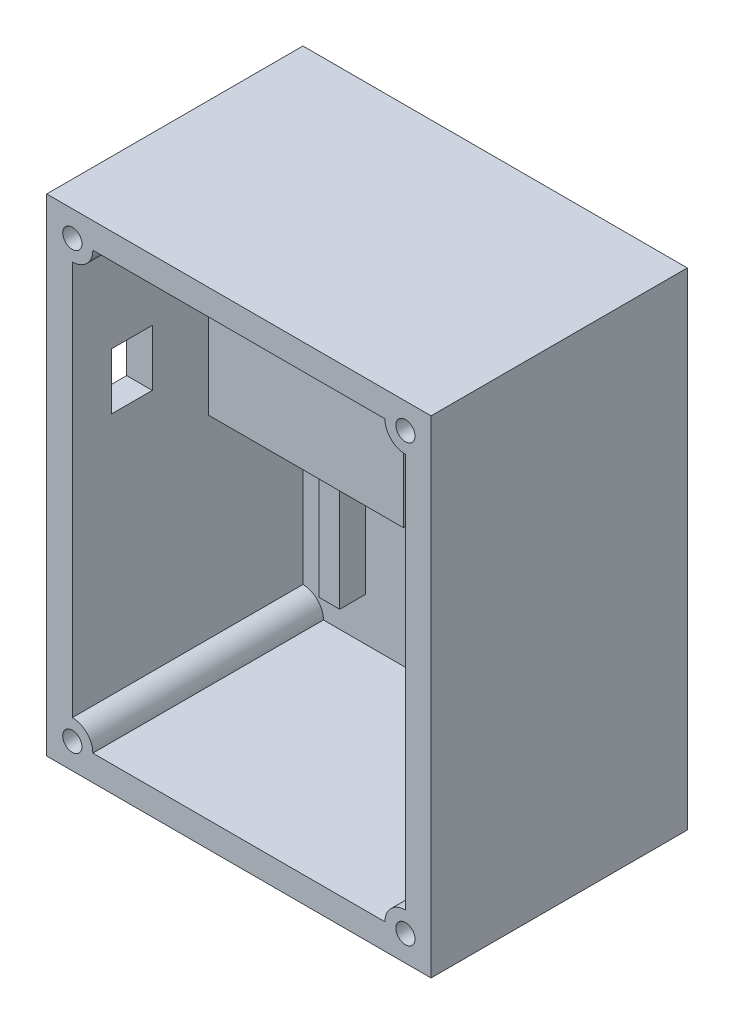
from build123d import *

# Parameters (mm, degrees)
SKETCH1_W           = 95.25
SKETCH1_H           = 120.65
BOSS_EXTRUDE1_DEPTH = 63.5
SHELL1_T            = -6.35
BOSS_EXTRUDE2_DEPTH = 57.15
SKETCH5_R           = 1.905
SKETCH5_W           = 22.2885
SKETCH5_H           = 5.08
BOSS_EXTRUDE5_DEPTH = 6.35
SKETCH7_R           = 1.016
BOSS_EXTRUDE6_DEPTH = 8.89
SKETCH8_R           = 2.38125
CUT_EXTRUDE1_DEPTH  = 8.89
BOSS_EXTRUDE7_DEPTH = 6.35
CUT_EXTRUDE3_REACH  = 97.25
SKETCH13_W          = 10.16
SKETCH13_H          = 13.97
BOSS_EXTRUDE8_DEPTH = 31.75
SKETCH16_W          = 48.26
SKETCH16_H          = 34.544
BOSS_EXTRUDE9_DEPTH = 25.4


with BuildPart() as part:
    # Sketch1 → Boss-Extrude1 (new body)
    with BuildSketch(Plane.XY):
        Rectangle(SKETCH1_W, SKETCH1_H)
    extrude(amount=BOSS_EXTRUDE1_DEPTH)

    # Shell1
    shell1_openings = [part.faces().sort_by_distance(p)[0] for p in [
        (0, 0, 63.5),
    ]]
    offset(amount=SHELL1_T, openings=shell1_openings, kind=Kind.INTERSECTION)

    # Sketch2 → Boss-Extrude2 (add)
    with BuildSketch(Plane.XY.offset(63.5)):
        with BuildLine():
            Line((-41.275, 53.975), (-36.195, 53.975))
            ThreePointArc((-36.195, 53.975), (-37.682897552, 50.382897552), (-41.275, 48.895))
            Line((-41.275, 48.895), (-41.275, 53.975))
        make_face()
        with BuildLine():
            Line((36.195, 53.975), (41.275, 53.975))
            Line((41.275, 53.975), (41.275, 48.895))
            ThreePointArc((41.275, 48.895), (37.682897552, 50.382897552), (36.195, 53.975))
        make_face()
        with BuildLine():
            Line((41.275, -48.895), (41.275, -53.975))
            Line((41.275, -53.975), (36.195, -53.975))
            ThreePointArc((36.195, -53.975), (37.682897552, -50.382897552), (41.275, -48.895))
        make_face()
        with BuildLine():
            Line((-41.275, -48.895), (-41.275, -53.975))
            Line((-41.275, -53.975), (-36.195, -53.975))
            ThreePointArc((-36.195, -53.975), (-37.682897552, -50.382897552), (-41.275, -48.895))
        make_face()
    extrude(amount=-BOSS_EXTRUDE2_DEPTH)

    # Sketch5 → Boss-Extrude5 (add)
    with BuildSketch(Plane.XY.offset(6.35)):
        with Locations((13.2715, -45.085)):
            Circle(SKETCH5_R)
        with Locations((31.75, -45.085)):
            Circle(SKETCH5_R)
        with Locations((22.51075, -23.495)):
            Rectangle(SKETCH5_W, SKETCH5_H)
    extrude(amount=BOSS_EXTRUDE5_DEPTH)

    # Sketch7 → Boss-Extrude6 (add)
    with BuildSketch(Plane.XY.offset(12.7)):
        with Locations((13.2715, -45.085)):
            Circle(SKETCH7_R)
        with Locations((31.75, -45.085)):
            Circle(SKETCH7_R)
    extrude(amount=BOSS_EXTRUDE6_DEPTH)

    # Sketch8 → Cut-Extrude1 (cut)
    with BuildSketch(Plane.XY.offset(63.5)):
        with Locations((-41.275, 53.975)):
            Circle(SKETCH8_R)
        with Locations((41.275, 53.975)):
            Circle(SKETCH8_R)
        with Locations((41.275, -53.975)):
            Circle(SKETCH8_R)
        with Locations((-41.275, -53.975)):
            Circle(SKETCH8_R)
    extrude(amount=-CUT_EXTRUDE1_DEPTH, mode=Mode.SUBTRACT)

    # Sketch10 → Boss-Extrude7 (add)
    with BuildSketch(Plane.XY.offset(6.35)):
        Polygon((-30.8991, -43.307), (-30.8991, -9.7028), (5.0165, -9.7028), (5.0165, -43.307), (-0.0635, -43.307), (-0.0635, -14.7828), (-25.8191, -14.7828), (-25.8191, -43.307), align=None)
    extrude(amount=BOSS_EXTRUDE7_DEPTH)

    # Sketch13 → Cut-Extrude3 (cut, up to next)
    with BuildSketch(Plane.ZY.offset(47.625), mode=Mode.PRIVATE) as cut_extrude3_sk1:
        with Locations((48.768, 18.415)):
            Rectangle(SKETCH13_W, SKETCH13_H)
    cut_extrude3_tool1 = extrude(cut_extrude3_sk1.sketch, amount=-CUT_EXTRUDE3_REACH, mode=Mode.PRIVATE) & part.part
    add(cut_extrude3_tool1.solids().sort_by_distance((-47.625, 18.415, 48.768))[0], mode=Mode.SUBTRACT)

    # Sketch15 → Boss-Extrude8 (add)
    with BuildSketch(Plane.XY.offset(6.35)):
        Polygon((-31.75, 53.975), (-31.75, 46.355), (31.75, 46.355), (31.75, 53.975), (35.56, 53.975), (35.56, 42.545), (-35.56, 42.545), (-35.56, 53.975), align=None)
    extrude(amount=BOSS_EXTRUDE8_DEPTH)

    # Sketch16 → Boss-Extrude9 (add)
    with BuildSketch(Plane.XY.offset(6.35)):
        with Locations((-15.113, 18.415)):
            Rectangle(SKETCH16_W, SKETCH16_H)
    extrude(amount=BOSS_EXTRUDE9_DEPTH)


solid = part.part
